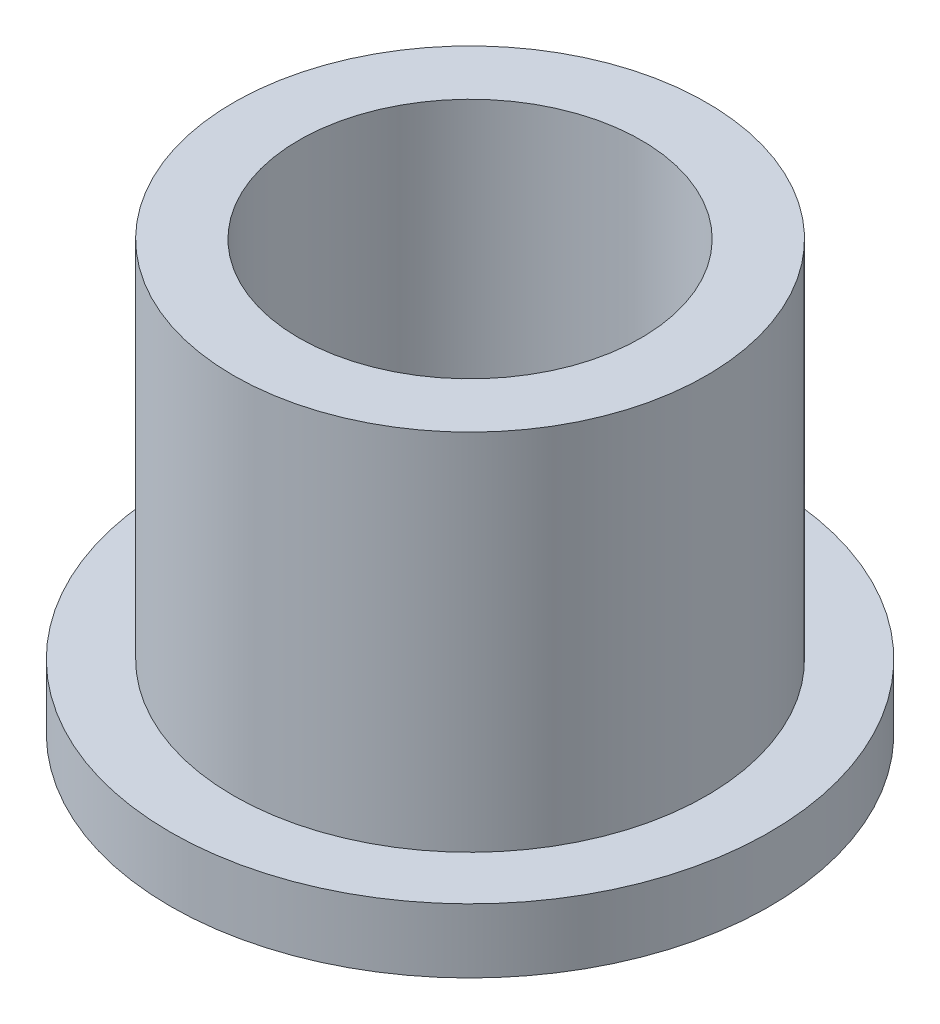
from build123d import *

# Parameters (mm, degrees)
SKETCH2_R           = 5.525
SKETCH2_R_2         = 4
BOSS_EXTRUDE1_DEPTH = 10
SKETCH3_R           = 7
SKETCH3_R_2         = 5.525
BOSS_EXTRUDE2_DEPTH = 1.5


with BuildPart() as part:
    # Sketch2 → Boss-Extrude1 (new body)
    with BuildSketch(Plane(origin=(0, 0, 0), x_dir=(1, 0, 0), z_dir=(0, 1, 0))):
        Circle(SKETCH2_R)
        Circle(SKETCH2_R_2, mode=Mode.SUBTRACT)
    extrude(amount=BOSS_EXTRUDE1_DEPTH)

    # Sketch3 → Boss-Extrude2 (add)
    with BuildSketch(Plane(origin=(0, 0, 0), x_dir=(1, 0, 0), z_dir=(0, 1, 0))):
        Circle(SKETCH3_R)
        Circle(SKETCH3_R_2, mode=Mode.SUBTRACT)
    extrude(amount=BOSS_EXTRUDE2_DEPTH)


solid = part.part
